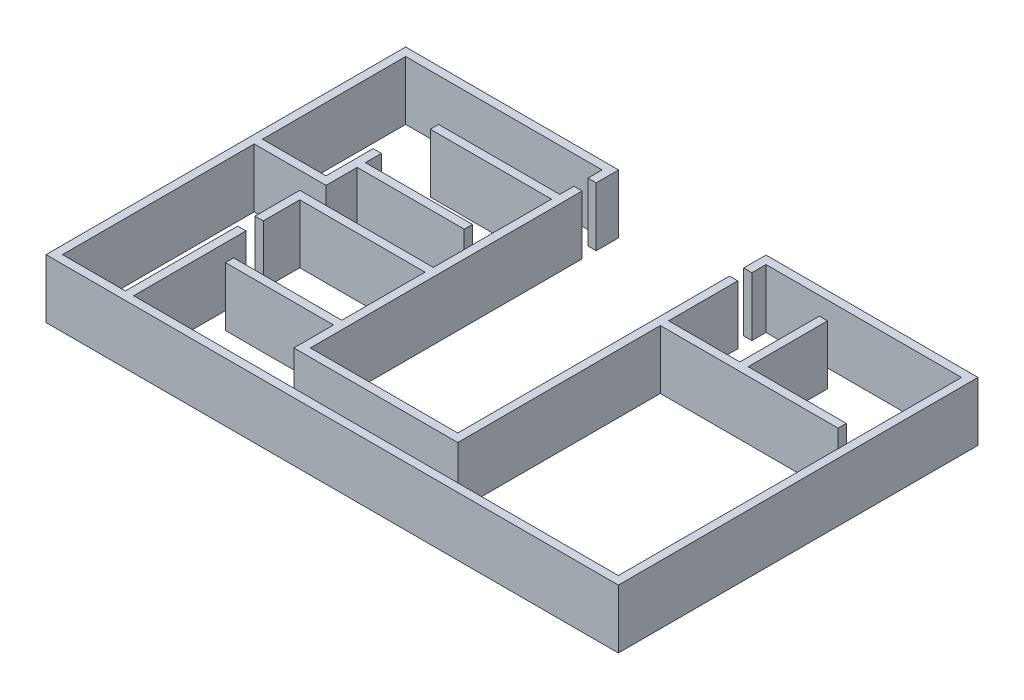
from build123d import *

# Parameters (mm, degrees)
WALLS_5M_DEPTH   = 5000
WALLS_5M_2_DEPTH = 5000


with BuildPart() as part:
    # hyperport_plan → walls_5m (new body)
    with BuildSketch(Plane(origin=(0, 0, 0), x_dir=(1, 0, 0), z_dir=(0, 1, 0))):
        Polygon((-6225, 15285), (-24325, 15285), (-24325, -15285), (24325, -15285), (24325, 15285), (6305, 15285), (6305, 13385), (7005, 13385), (7005, 14585), (23625, 14585), (23625, -14585), (-17575, -14585), (-17575, -5035), (-18275, -5035), (-18275, -14585), (-23625, -14585), (-23625, 1715), (-17525, 1715), (-17525, 4365), (-8425, 4365), (-8425, 5065), (-17525, 5065), (-17525, 6425), (-18225, 6425), (-18225, 2415), (-23625, 2415), (-23625, 14585), (-6925, 14585), (-6925, 13385), (-6225, 13385), align=None)
    extrude(amount=WALLS_5M_DEPTH)


with BuildPart() as body_2:
    # hyperport_plan → walls_5m 2 (new body)
    with BuildSketch(Plane(origin=(0, 0, 0), x_dir=(1, 0, 0), z_dir=(0, 1, 0))):
        Polygon((-6225, 12185), (-6225, 10985), (-6225, -10915), (6305, -10915), (6305, 12185), (7005, 12185), (7005, 6305), (13065, 6305), (13065, 13055), (13765, 13055), (13765, 6305), (22115, 6305), (22115, 5605), (7005, 5605), (7005, -11615), (-6925, -11615), (-6925, -8245), (-16115, -8245), (-16115, -7545), (-6925, -7545), (-6925, -465), (-17575, -465), (-17575, -3565), (-18275, -3565), (-18275, 235), (-6925, 235), (-6925, 10285), (-17225, 10285), (-17225, 10985), (-6925, 10985), (-6925, 12185), align=None)
    extrude(amount=WALLS_5M_2_DEPTH)


solid = Compound([part.part, body_2.part])
